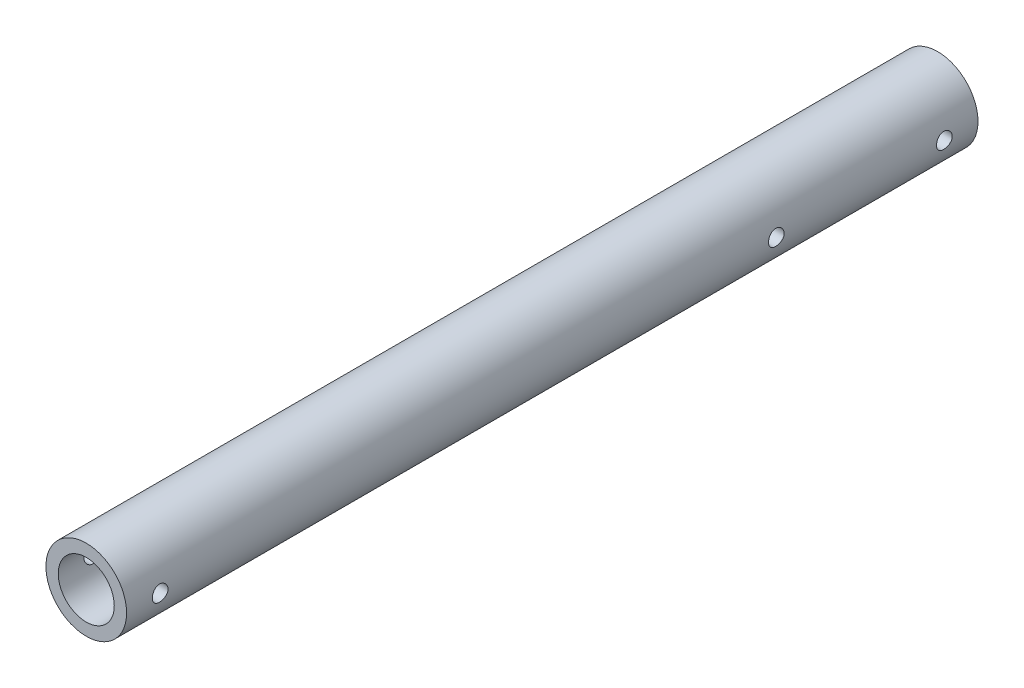
from build123d import *

# Parameters (mm, degrees)
SKETCH_1_R               = 9
SKETCH_1_R_2             = 6.25
EXTRUDE_1_DEPTH          = 190
SKETCH_2_R               = 1.75
CUT_EXTRUDE_1_DEPTH      = 10
CUT_EXTRUDE_1_DEPTH_BACK = 10


with BuildPart() as part:
    # ｽｹｯﾁ1 → ﾎﾞｽ - 押し出し1 (new body)
    with BuildSketch(Plane.XY):
        Circle(SKETCH_1_R)
        Circle(SKETCH_1_R_2, mode=Mode.SUBTRACT)
    extrude(amount=EXTRUDE_1_DEPTH)

    # ｽｹｯﾁ2 → ｶｯﾄ - 押し出し1 (cut, two sides)
    with BuildSketch(Plane(origin=(0, 0, 0), x_dir=(0, 0, -1), z_dir=(1, 0, 0))) as cut_extrude_1_sk:
        with Locations((-7.5, 0)):
            Circle(SKETCH_2_R)
        with Locations((-182.5, 0)):
            Circle(SKETCH_2_R)
        with Locations((-45, 0)):
            Circle(SKETCH_2_R)
    extrude(amount=CUT_EXTRUDE_1_DEPTH, mode=Mode.SUBTRACT)
    extrude(cut_extrude_1_sk.sketch, amount=-CUT_EXTRUDE_1_DEPTH_BACK, mode=Mode.SUBTRACT)


solid = part.part
